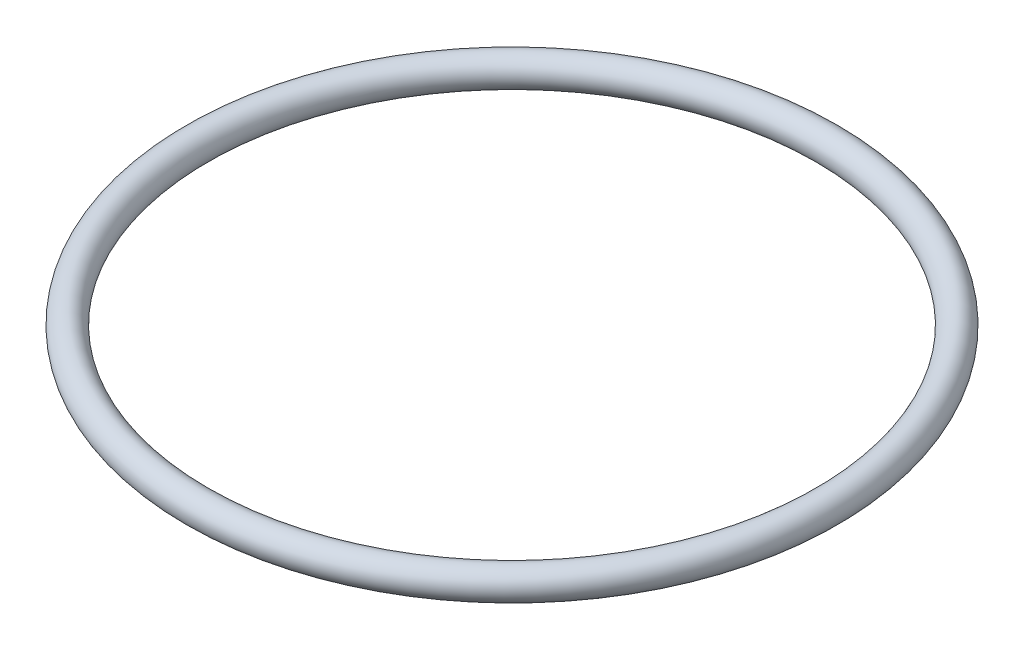
from build123d import *

# Parameters (mm, degrees)
SKETCH2_R = 1.143


with BuildPart() as part:
    # Sweep1: sweep along a path in Sketch1
    with BuildLine(Plane(origin=(0, 0, 0), x_dir=(1, 0, 0), z_dir=(0, 1, 0))) as sweep1_path:
        CenterArc((0, 0), 23.8715, 0, 360)
    # Sketch2 → Sweep1 (sweep)
    with BuildSketch(Plane.XY):
        with Locations((-23.8715, 0)):
            Circle(SKETCH2_R)
    sweep(path=sweep1_path.line)


solid = part.part
